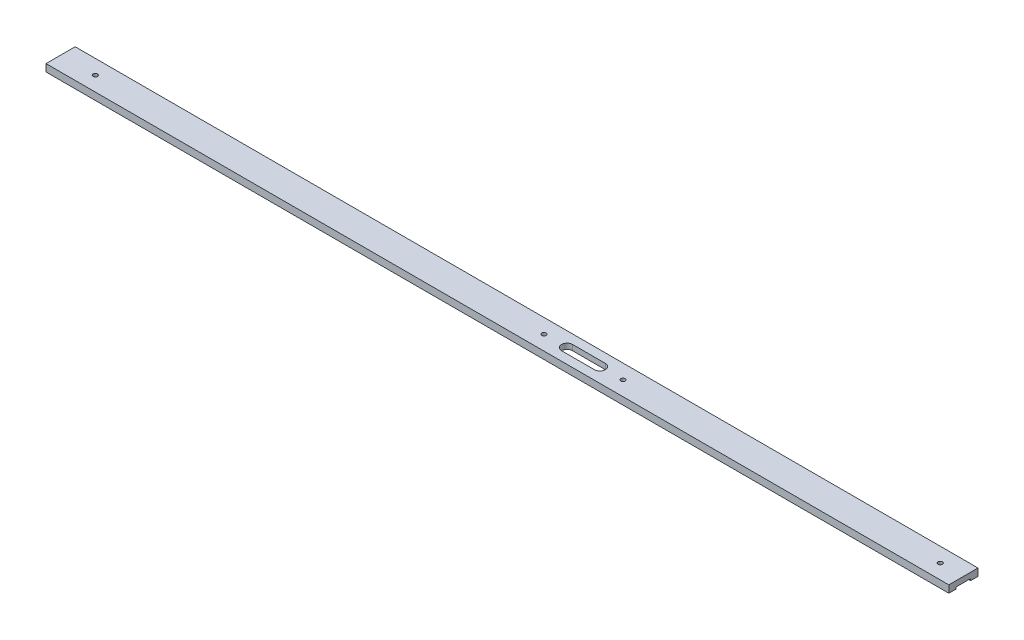
from build123d import *

# Parameters (mm, degrees)
SKETCH1_W                 = 247.65
SKETCH1_H                 = 8
BOSS_EXTRUDE1_DEPTH       = 2
SKETCH2_W                 = 4
SKETCH2_H                 = 1
CUT_EXTRUDE1_DEPTH        = 248.65
CUT_EXTRUDE2_DEPTH        = 2.5
F_0_80_TAPPED_HOLE1_D     = 1.19126
F_0_80_TAPPED_HOLE1_DEPTH = 4.572
F_0_80_TAPPED_HOLE1_TIP   = 0.357890611


with BuildPart() as part:
    # Sketch1 → Boss-Extrude1 (new body)
    with BuildSketch(Plane(origin=(0, 0, 0), x_dir=(1, 0, 0), z_dir=(0, 1, 0))):
        Rectangle(SKETCH1_W, SKETCH1_H)
    extrude(amount=BOSS_EXTRUDE1_DEPTH)

    # Sketch2 → Cut-Extrude1 (cut, through all)
    with BuildSketch(Plane(origin=(123.825, 0, 0), x_dir=(0, 0, -1), z_dir=(1, 0, 0))):
        Rectangle(SKETCH2_W, SKETCH2_H)
    extrude(amount=-CUT_EXTRUDE1_DEPTH, mode=Mode.SUBTRACT)

    # Sketch5 → Cut-Extrude2 (cut, through all)
    with BuildSketch(Plane(origin=(0, 0.5, 0), x_dir=(-1, 0, 0), z_dir=(0, 1, 0))):
        with BuildLine():
            Line((-15.1088, -1.5), (-24.1088, -1.5))
            ThreePointArc((-24.1088, -1.5), (-25.6088, 0), (-24.1088, 1.5))
            Line((-24.1088, 1.5), (-15.1088, 1.5))
            ThreePointArc((-15.1088, 1.5), (-13.6088, 0), (-15.1088, -1.5))
        make_face()
    extrude(amount=CUT_EXTRUDE2_DEPTH, mode=Mode.SUBTRACT)

    # #0-80 Tapped Hole1
    with Locations(Plane(origin=(0, 2, 0), x_dir=(-1, 0, 0), z_dir=(0, 1, 0))):
        with Locations((114.3, 0), (-8.7588, 0), (-30.4588, 0), (-117.475, 0)):
            Hole(F_0_80_TAPPED_HOLE1_D / 2, depth=F_0_80_TAPPED_HOLE1_DEPTH)
            with Locations((0, 0, -(F_0_80_TAPPED_HOLE1_DEPTH + F_0_80_TAPPED_HOLE1_TIP / 2))):  # 118° drill point
                Cone(0, F_0_80_TAPPED_HOLE1_D / 2, F_0_80_TAPPED_HOLE1_TIP, mode=Mode.SUBTRACT)


solid = part.part
